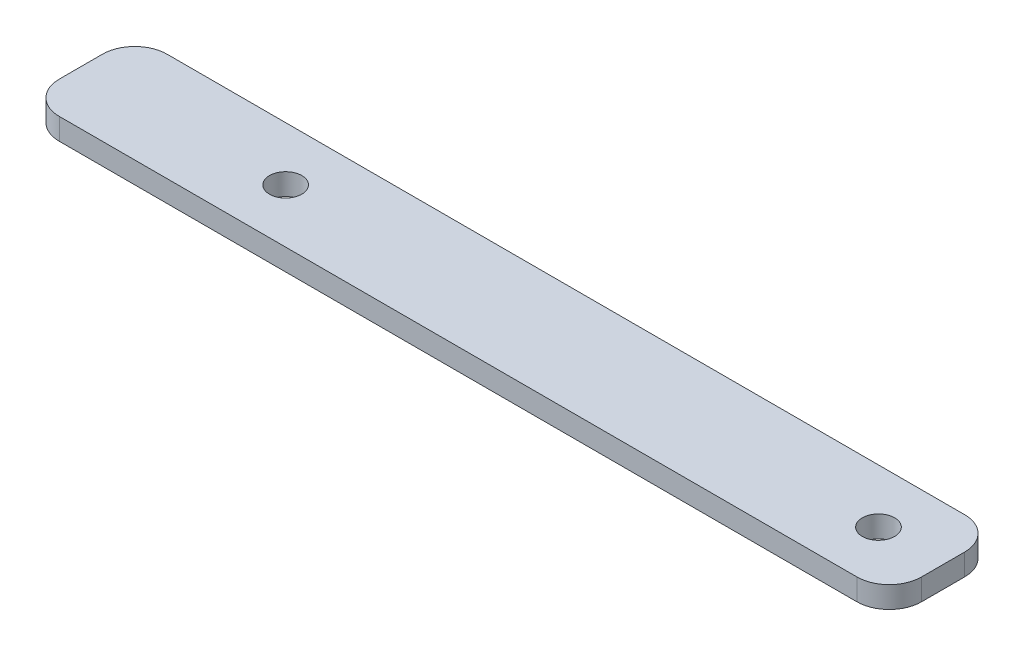
from build123d import *

# Parameters (mm, degrees)
SKETCH1_W             = 80
SKETCH1_H             = 10
BOSS_EXTRUDE1_DEPTH   = 2
FILLET1_R             = 3
F_3_0MM_DOWEL_HOLE1_D = 3


with BuildPart() as part:
    # Sketch1 → Boss-Extrude1 (new body)
    with BuildSketch(Plane(origin=(0, 0, 0), x_dir=(1, 0, 0), z_dir=(0, 1, 0))):
        Rectangle(SKETCH1_W, SKETCH1_H)
    extrude(amount=BOSS_EXTRUDE1_DEPTH)

    # Fillet1
    fillet1_edges = [part.edges().sort_by_distance(p)[0] for p in [
        (40, 1, 5),
        (-40, 1, 5),
        (-40, 1, -5),
        (40, 1, -5),
    ]]
    fillet(fillet1_edges, radius=FILLET1_R)

    # Ø3.0mm Dowel Hole1 (through all)
    with Locations(Plane(origin=(0, 0, 0), x_dir=(-1, 0, 0), z_dir=(0, -1, 0))):
        with Locations((-34, 0), (21, 0)):
            Hole(F_3_0MM_DOWEL_HOLE1_D / 2)


solid = part.part
